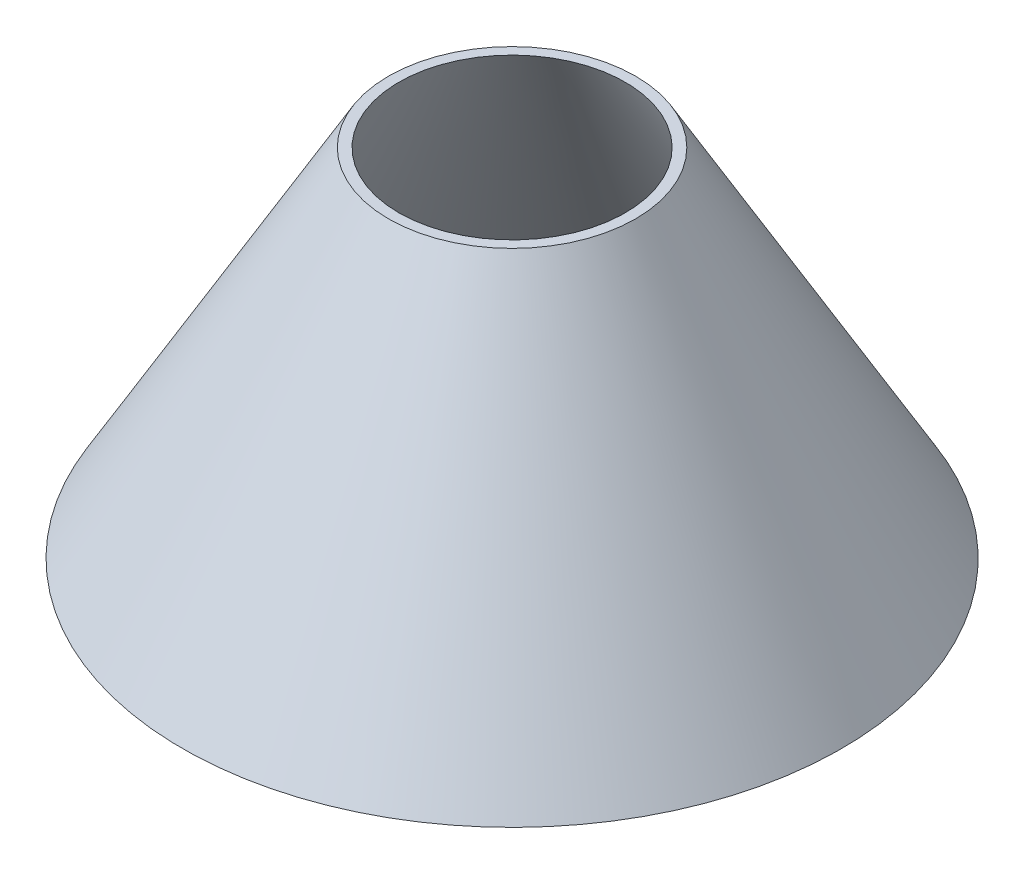
from build123d import *

# Parameters (mm, degrees)
SHELL4_T = -1.2


with BuildPart() as part:
    # Sketch1 → Revolve1 (revolve)
    with BuildSketch(Plane.XY, mode=Mode.PRIVATE) as revolve1_sk:
        Polygon((-16.5, 47.5), (-44, 0), (0, 0), (0, 47.5), align=None)
    revolve(revolve1_sk.sketch.rotate(Axis((0, 0, 0), (0, 1, 0)), 270), axis=Axis((0, 0, 0), (0, 1, 0)))

    # Shell4
    shell4_openings = [part.faces().sort_by_distance(p)[0] for p in [
        (0, 47.5, 0),
        (0, 0, 0),
    ]]
    offset(amount=SHELL4_T, openings=shell4_openings, kind=Kind.INTERSECTION)


solid = part.part
